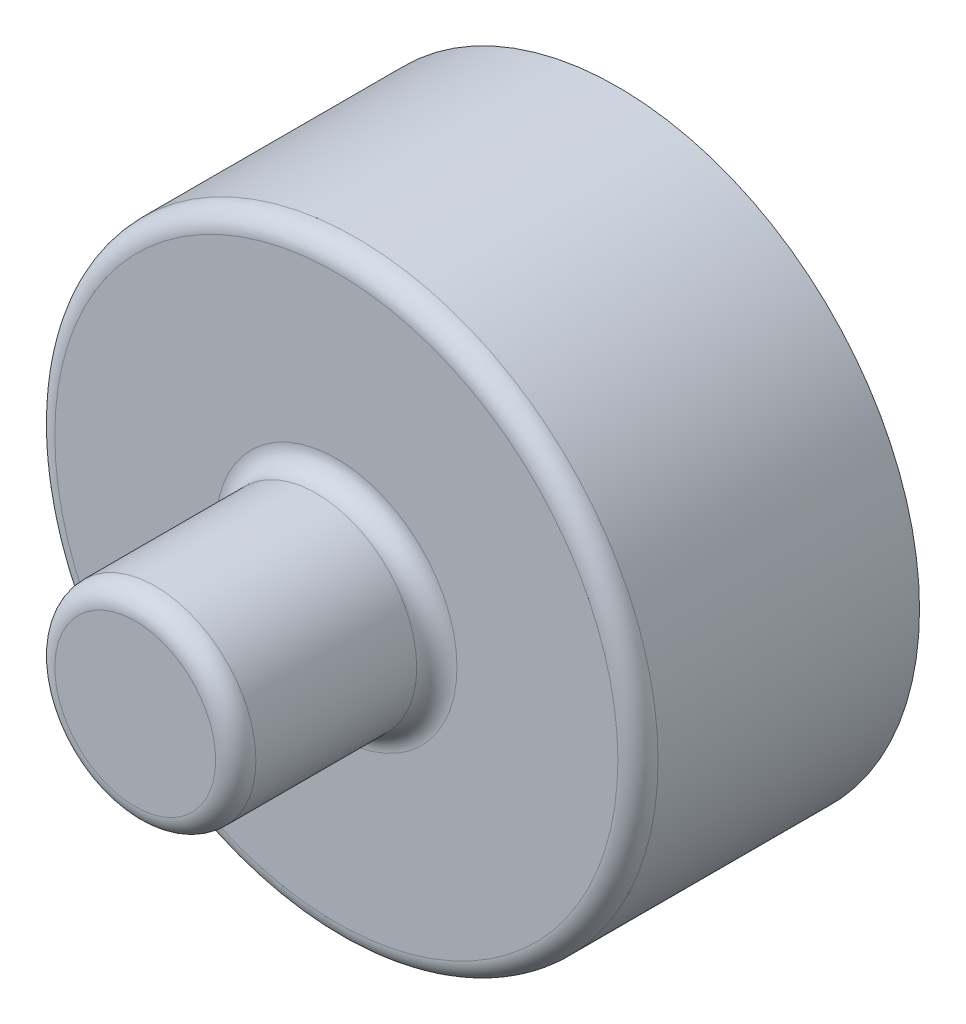
from build123d import *

# Parameters (mm, degrees)
ESQUISSE1_R        = 7.5
BOSS_EXTRU_1_DEPTH = 7
ESQUISSE2_R        = 2.5
BOSS_EXTRU_2_DEPTH = 5
CONG_1_R           = 0.5


with BuildPart() as part:
    # Esquisse1 → Boss.-Extru.1 (new body)
    with BuildSketch(Plane.XY):
        Circle(ESQUISSE1_R)
    extrude(amount=BOSS_EXTRU_1_DEPTH)

    # Esquisse2 → Boss.-Extru.2 (add)
    with BuildSketch(Plane.XY.offset(7)):
        Circle(ESQUISSE2_R)
    extrude(amount=BOSS_EXTRU_2_DEPTH)

    # Congé1
    cong_1_edges = [part.edges().sort_by_distance(p)[0] for p in [
        (-7.5, 0, 7),
        (-2.5, 0, 7),
        (-2.5, 0, 12),
    ]]
    fillet(cong_1_edges, radius=CONG_1_R)


solid = part.part
